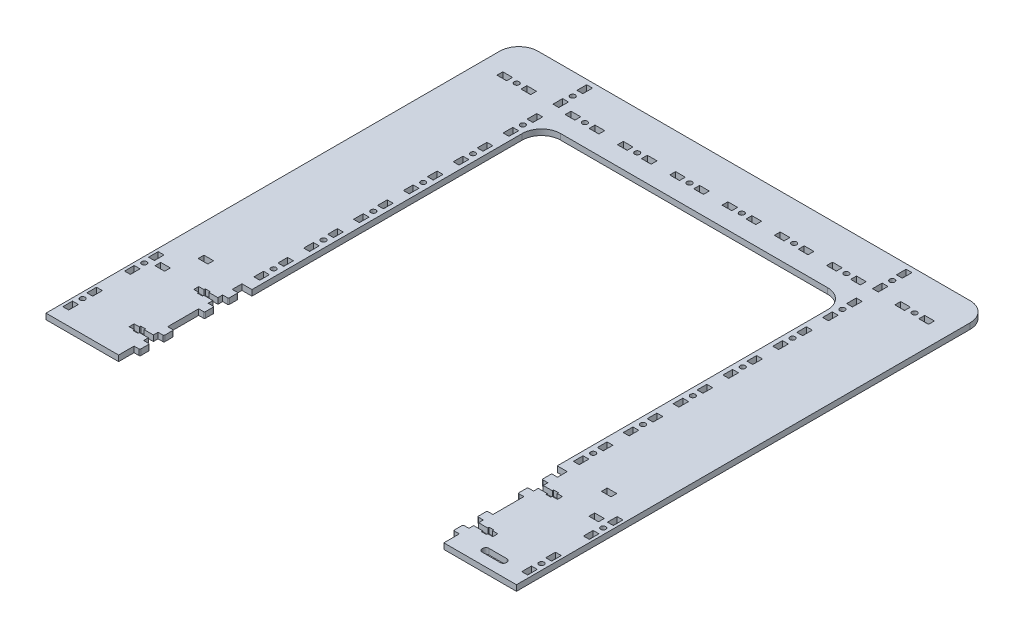
from build123d import *

# Parameters (mm, degrees)
SKETCH1_W                 = 490
SKETCH1_H                 = 492.5
BOSS_EXTRUDE1_DEPTH       = 6
SKETCH2_W                 = 338.8
SKETCH2_H                 = 128.5
CUT_EXTRUDE1_DEPTH        = 7
SKETCH3_W                 = 318
SKETCH3_H                 = 301.5
CUT_EXTRUDE2_DEPTH        = 7
M5_CLEARANCE_HOLE1_D      = 5.3
M5_CLEARANCE_HOLE2_D      = 5.3
SKETCH71_W                = 6.1
SKETCH71_H                = 10.1
CUT_EXTRUDE21_DEPTH       = 4
CUT_EXTRUDE21_DEPTH_BACK  = 4
SKETCH72_W                = 6.1
SKETCH72_H                = 10.1
CUT_EXTRUDE22_DEPTH       = 4
CUT_EXTRUDE22_DEPTH_BACK  = 4
SKETCH73_W                = 6.1
SKETCH73_H                = 10.1
CUT_EXTRUDE23_DEPTH       = 4
CUT_EXTRUDE23_DEPTH_BACK  = 4
SKETCH74_W                = 6.1
SKETCH74_H                = 10.1
CUT_EXTRUDE24_DEPTH       = 4
CUT_EXTRUDE24_DEPTH_BACK  = 4
CUT_EXTRUDE25_DEPTH       = 4
CUT_EXTRUDE25_DEPTH_BACK  = 4
SKETCH234_W               = 6.1
SKETCH234_H               = 10
BOSS_EXTRUDE2_DEPTH       = 3
BOSS_EXTRUDE2_DEPTH_BACK  = 3
FILLET1_R                 = 1
CUT_EXTRUDE26_DEPTH       = 4
CUT_EXTRUDE26_DEPTH_BACK  = 4
SKETCH2341_W              = 6.1
SKETCH2341_H              = 10
BOSS_EXTRUDE21_DEPTH      = 3
BOSS_EXTRUDE21_DEPTH_BACK = 3
FILLET11_R                = 1
CUT_EXTRUDE27_DEPTH       = 4
CUT_EXTRUDE27_DEPTH_BACK  = 4
SKETCH2342_W              = 6.1
SKETCH2342_H              = 10
BOSS_EXTRUDE22_DEPTH      = 3
BOSS_EXTRUDE22_DEPTH_BACK = 3
FILLET12_R                = 1
CUT_EXTRUDE28_DEPTH       = 4
CUT_EXTRUDE28_DEPTH_BACK  = 4
SKETCH2343_W              = 6.1
SKETCH2343_H              = 10
BOSS_EXTRUDE23_DEPTH      = 3
BOSS_EXTRUDE23_DEPTH_BACK = 3
FILLET13_R                = 1
SKETCH6_W                 = 10
SKETCH6_H                 = 6
CUT_EXTRUDE16_DEPTH       = 4
CUT_EXTRUDE16_DEPTH_BACK  = 4
SKETCH75_W                = 6.1
SKETCH75_H                = 10.1
CUT_EXTRUDE210_DEPTH      = 4
CUT_EXTRUDE210_DEPTH_BACK = 4
SKETCH76_W                = 6.1
SKETCH76_H                = 10.1
CUT_EXTRUDE211_DEPTH      = 4
CUT_EXTRUDE211_DEPTH_BACK = 4
SKETCH77_W                = 6.1
SKETCH77_H                = 10.1
CUT_EXTRUDE212_DEPTH      = 4
CUT_EXTRUDE212_DEPTH_BACK = 4
SKETCH78_W                = 6.1
SKETCH78_H                = 10.1
CUT_EXTRUDE213_DEPTH      = 4
CUT_EXTRUDE213_DEPTH_BACK = 4
SKETCH79_W                = 6.1
SKETCH79_H                = 10.1
CUT_EXTRUDE214_DEPTH      = 4
CUT_EXTRUDE214_DEPTH_BACK = 4
SKETCH710_W               = 6.1
SKETCH710_H               = 10.1
CUT_EXTRUDE215_DEPTH      = 4
CUT_EXTRUDE215_DEPTH_BACK = 4
SKETCH711_W               = 6.1
SKETCH711_H               = 10.1
CUT_EXTRUDE216_DEPTH      = 4
CUT_EXTRUDE216_DEPTH_BACK = 4
SKETCH712_W               = 6.1
SKETCH712_H               = 10.1
CUT_EXTRUDE217_DEPTH      = 4
CUT_EXTRUDE217_DEPTH_BACK = 4
SKETCH713_W               = 6.1
SKETCH713_H               = 10.1
CUT_EXTRUDE218_DEPTH      = 4
CUT_EXTRUDE218_DEPTH_BACK = 4
SKETCH714_W               = 6.1
SKETCH714_H               = 10.1
CUT_EXTRUDE219_DEPTH      = 4
CUT_EXTRUDE219_DEPTH_BACK = 4
SKETCH715_W               = 6.1
SKETCH715_H               = 10.1
CUT_EXTRUDE220_DEPTH      = 4
CUT_EXTRUDE220_DEPTH_BACK = 4
SKETCH716_W               = 6.1
SKETCH716_H               = 10.1
CUT_EXTRUDE221_DEPTH      = 4
CUT_EXTRUDE221_DEPTH_BACK = 4
SKETCH63_W                = 10
SKETCH63_H                = 6
CUT_EXTRUDE19_DEPTH       = 4
M5_CLEARANCE_HOLE3_D      = 5.3
SKETCH719_W               = 6.1
SKETCH719_H               = 10.1
CUT_EXTRUDE225_DEPTH      = 4
CUT_EXTRUDE225_DEPTH_BACK = 4
SKETCH720_W               = 6.1
SKETCH720_H               = 10.1
CUT_EXTRUDE226_DEPTH      = 4
CUT_EXTRUDE226_DEPTH_BACK = 4
SKETCH721_W               = 6.1
SKETCH721_H               = 10.1
CUT_EXTRUDE227_DEPTH      = 4
CUT_EXTRUDE227_DEPTH_BACK = 4
SKETCH722_W               = 6.1
SKETCH722_H               = 10.1
CUT_EXTRUDE228_DEPTH      = 4
CUT_EXTRUDE228_DEPTH_BACK = 4
SKETCH723_W               = 6.1
SKETCH723_H               = 10.1
CUT_EXTRUDE229_DEPTH      = 4
CUT_EXTRUDE229_DEPTH_BACK = 4
SKETCH724_W               = 6.1
SKETCH724_H               = 10.1
CUT_EXTRUDE230_DEPTH      = 4
CUT_EXTRUDE230_DEPTH_BACK = 4
SKETCH725_W               = 6.1
SKETCH725_H               = 10.1
CUT_EXTRUDE231_DEPTH      = 4
CUT_EXTRUDE231_DEPTH_BACK = 4
SKETCH718_W               = 6.1
SKETCH718_H               = 10.1
CUT_EXTRUDE224_DEPTH      = 4
CUT_EXTRUDE224_DEPTH_BACK = 4
SKETCH726_W               = 6.1
SKETCH726_H               = 10.1
CUT_EXTRUDE232_DEPTH      = 4
CUT_EXTRUDE232_DEPTH_BACK = 4
SKETCH727_W               = 6.1
SKETCH727_H               = 10.1
CUT_EXTRUDE233_DEPTH      = 4
CUT_EXTRUDE233_DEPTH_BACK = 4
FILLET14_R                = 20
SKETCH2351_W              = 25
SKETCH2351_H              = 7
CUT_EXTRUDE234_DEPTH      = 7
FILLET15_R                = 3
SKETCH65_W                = 10
SKETCH65_H                = 6
CUT_EXTRUDE111_DEPTH      = 4
CUT_EXTRUDE111_DEPTH_BACK = 4


with BuildPart() as part:
    # Sketch1 → Boss-Extrude1 (new body)
    with BuildSketch(Plane(origin=(0, 0, 0), x_dir=(1, 0, 0), z_dir=(0, 1, 0))):
        Rectangle(SKETCH1_W, SKETCH1_H)
    extrude(amount=BOSS_EXTRUDE1_DEPTH)

    # Sketch2 → Cut-Extrude1 (cut, through all)
    with BuildSketch(Plane(origin=(0, 6, 0), x_dir=(1, 0, 0), z_dir=(0, 1, 0))):
        with Locations((0, -182)):
            Rectangle(SKETCH2_W, SKETCH2_H)
    extrude(amount=-CUT_EXTRUDE1_DEPTH, mode=Mode.SUBTRACT)

    # Sketch3 → Cut-Extrude2 (cut, through all)
    with BuildSketch(Plane(origin=(0, 6, 0), x_dir=(1, 0, 0), z_dir=(0, 1, 0))):
        with Locations((0, 33)):
            Rectangle(SKETCH3_W, SKETCH3_H)
    extrude(amount=-CUT_EXTRUDE2_DEPTH, mode=Mode.SUBTRACT)

    # M5 Clearance Hole1 (through all)
    with Locations(Plane(origin=(0, 0, 0), x_dir=(-1, 0, 0), z_dir=(0, -1, 0))):
        with Locations((-239, -149.875), (-239, -214.125)):
            m5_clearance_hole1 = Hole(M5_CLEARANCE_HOLE1_D / 2)

    # M5 Clearance Hole2 (through all)
    with Locations(Plane(origin=(0, 6, 0), x_dir=(1, 0, 0), z_dir=(0, 1, 0))):
        with Locations((-166.4, -87.75), (-166.4, -35.833333333), (-166.4, 16.083333333), (-166.4, 68), (-166.4, 119.916666667), (-166.4, 171.833333333), (-166.4, 223.75)):
            m5_clearance_hole2 = Hole(M5_CLEARANCE_HOLE2_D / 2)

    # Mirror2: M5 Clearance Hole1, M5 Clearance Hole2 across plane
    add(m5_clearance_hole1.mirror(Plane(origin=(0, 0, 0), x_dir=(0, 0, 1), z_dir=(1, 0, 0))), mode=Mode.SUBTRACT)
    add(m5_clearance_hole2.mirror(Plane(origin=(0, 0, 0), x_dir=(0, 0, 1), z_dir=(1, 0, 0))), mode=Mode.SUBTRACT)

    # Sketch71 → Cut-Extrude21 (cut, two sides)
    with BuildSketch(Plane(origin=(283, 3, 169.875), x_dir=(-1, 0, 0), z_dir=(0, 1, 0))) as cut_extrude21_sk:
        with Locations((44, -32.5)):
            Rectangle(SKETCH71_W, SKETCH71_H)
        with Locations((44, -7.5)):
            Rectangle(SKETCH71_W, SKETCH71_H)
    extrude(amount=CUT_EXTRUDE21_DEPTH, mode=Mode.SUBTRACT)
    extrude(cut_extrude21_sk.sketch, amount=-CUT_EXTRUDE21_DEPTH_BACK, mode=Mode.SUBTRACT)

    # Sketch72 → Cut-Extrude22 (cut, two sides)
    with BuildSketch(Plane(origin=(283, 3, 234.125), x_dir=(-1, 0, 0), z_dir=(0, 1, 0))) as cut_extrude22_sk:
        with Locations((44, -32.5)):
            Rectangle(SKETCH72_W, SKETCH72_H)
        with Locations((44, -7.5)):
            Rectangle(SKETCH72_W, SKETCH72_H)
    extrude(amount=CUT_EXTRUDE22_DEPTH, mode=Mode.SUBTRACT)
    extrude(cut_extrude22_sk.sketch, amount=-CUT_EXTRUDE22_DEPTH_BACK, mode=Mode.SUBTRACT)

    # Sketch73 → Cut-Extrude23 (cut, two sides)
    with BuildSketch(Plane(origin=(-195, 3, 169.875), x_dir=(-1, 0, 0), z_dir=(0, 1, 0))) as cut_extrude23_sk:
        with Locations((44, -32.5)):
            Rectangle(SKETCH73_W, SKETCH73_H)
        with Locations((44, -7.5)):
            Rectangle(SKETCH73_W, SKETCH73_H)
    extrude(amount=CUT_EXTRUDE23_DEPTH, mode=Mode.SUBTRACT)
    extrude(cut_extrude23_sk.sketch, amount=-CUT_EXTRUDE23_DEPTH_BACK, mode=Mode.SUBTRACT)

    # Sketch74 → Cut-Extrude24 (cut, two sides)
    with BuildSketch(Plane(origin=(-195, 3, 234.125), x_dir=(-1, 0, 0), z_dir=(0, 1, 0))) as cut_extrude24_sk:
        with Locations((44, -32.5)):
            Rectangle(SKETCH74_W, SKETCH74_H)
        with Locations((44, -7.5)):
            Rectangle(SKETCH74_W, SKETCH74_H)
    extrude(amount=CUT_EXTRUDE24_DEPTH, mode=Mode.SUBTRACT)
    extrude(cut_extrude24_sk.sketch, amount=-CUT_EXTRUDE24_DEPTH_BACK, mode=Mode.SUBTRACT)

    # Sketch23 → Cut-Extrude25 (cut, two sides)
    with BuildSketch(Plane(origin=(219.4, 3, 165.375), x_dir=(-1, 0, 0), z_dir=(0, -1, 0))) as cut_extrude25_sk:
        Polygon((30, 17.4), (30, 22.6), (35.5, 22.6), (35.5, 24), (40.5, 24), (40.5, 22.6), (50, 22.6), (50, 17.4), (40.5, 17.4), (40.5, 16), (35.5, 16), (35.5, 17.4), align=None)
    extrude(amount=CUT_EXTRUDE25_DEPTH, mode=Mode.SUBTRACT)
    extrude(cut_extrude25_sk.sketch, amount=-CUT_EXTRUDE25_DEPTH_BACK, mode=Mode.SUBTRACT)

    # Sketch234 → Boss-Extrude2 (add, two sides)
    with BuildSketch(Plane(origin=(219.4, 3, 165.375), x_dir=(-1, 0, 0), z_dir=(0, -1, 0))) as boss_extrude2_sk:
        with Locations((53.05, 32.5)):
            Rectangle(SKETCH234_W, SKETCH234_H)
        with Locations((53.05, 7.5)):
            Rectangle(SKETCH234_W, SKETCH234_H)
    extrude(amount=BOSS_EXTRUDE2_DEPTH)
    extrude(boss_extrude2_sk.sketch, amount=-BOSS_EXTRUDE2_DEPTH_BACK)

    # Fillet1
    fillet1_edges = [part.edges().sort_by_distance(p)[0] for p in [
        (163.3, 3, 127.875),
        (163.3, 3, 137.875),
        (163.3, 3, 152.875),
        (163.3, 3, 162.875),
    ]]
    fillet(fillet1_edges, radius=FILLET1_R)

    # Sketch236 → Cut-Extrude26 (cut, two sides)
    with BuildSketch(Plane(origin=(219.4, 3, 232.625), x_dir=(-1, 0, 0), z_dir=(0, -1, 0))) as cut_extrude26_sk:
        Polygon((30, 17.4), (30, 22.6), (35.5, 22.6), (35.5, 24), (40.5, 24), (40.5, 22.6), (50, 22.6), (50, 17.4), (40.5, 17.4), (40.5, 16), (35.5, 16), (35.5, 17.4), align=None)
    extrude(amount=CUT_EXTRUDE26_DEPTH, mode=Mode.SUBTRACT)
    extrude(cut_extrude26_sk.sketch, amount=-CUT_EXTRUDE26_DEPTH_BACK, mode=Mode.SUBTRACT)

    # Sketch2341 → Boss-Extrude21 (add, two sides)
    with BuildSketch(Plane(origin=(219.4, 3, 232.625), x_dir=(-1, 0, 0), z_dir=(0, -1, 0))) as boss_extrude21_sk:
        with Locations((53.05, 32.5)):
            Rectangle(SKETCH2341_W, SKETCH2341_H)
        with Locations((53.05, 7.5)):
            Rectangle(SKETCH2341_W, SKETCH2341_H)
    extrude(amount=BOSS_EXTRUDE21_DEPTH)
    extrude(boss_extrude21_sk.sketch, amount=-BOSS_EXTRUDE21_DEPTH_BACK)

    # Fillet11
    fillet11_edges = [part.edges().sort_by_distance(p)[0] for p in [
        (163.3, 3, 195.125),
        (163.3, 3, 205.125),
        (163.3, 3, 220.125),
        (163.3, 3, 230.125),
    ]]
    fillet(fillet11_edges, radius=FILLET11_R)

    # Sketch237 → Cut-Extrude27 (cut, two sides)
    with BuildSketch(Plane(origin=(-219.4, 3, 125.375), x_dir=(1, 0, 0), z_dir=(0, -1, 0))) as cut_extrude27_sk:
        Polygon((30, 17.4), (30, 22.6), (35.5, 22.6), (35.5, 24), (40.5, 24), (40.5, 22.6), (50, 22.6), (50, 17.4), (40.5, 17.4), (40.5, 16), (35.5, 16), (35.5, 17.4), align=None)
    extrude(amount=CUT_EXTRUDE27_DEPTH, mode=Mode.SUBTRACT)
    extrude(cut_extrude27_sk.sketch, amount=-CUT_EXTRUDE27_DEPTH_BACK, mode=Mode.SUBTRACT)

    # Sketch2342 → Boss-Extrude22 (add, two sides)
    with BuildSketch(Plane(origin=(-219.4, 3, 125.375), x_dir=(1, 0, 0), z_dir=(0, -1, 0))) as boss_extrude22_sk:
        with Locations((53.05, 32.5)):
            Rectangle(SKETCH2342_W, SKETCH2342_H)
        with Locations((53.05, 7.5)):
            Rectangle(SKETCH2342_W, SKETCH2342_H)
    extrude(amount=BOSS_EXTRUDE22_DEPTH)
    extrude(boss_extrude22_sk.sketch, amount=-BOSS_EXTRUDE22_DEPTH_BACK)

    # Fillet12
    fillet12_edges = [part.edges().sort_by_distance(p)[0] for p in [
        (-163.3, 3, 162.875),
        (-163.3, 3, 152.875),
        (-163.3, 3, 137.875),
        (-163.3, 3, 127.875),
    ]]
    fillet(fillet12_edges, radius=FILLET12_R)

    # Sketch238 → Cut-Extrude28 (cut, two sides)
    with BuildSketch(Plane(origin=(-219.4, 3, 192.625), x_dir=(1, 0, 0), z_dir=(0, -1, 0))) as cut_extrude28_sk:
        Polygon((30, 17.4), (30, 22.6), (35.5, 22.6), (35.5, 24), (40.5, 24), (40.5, 22.6), (50, 22.6), (50, 17.4), (40.5, 17.4), (40.5, 16), (35.5, 16), (35.5, 17.4), align=None)
    extrude(amount=CUT_EXTRUDE28_DEPTH, mode=Mode.SUBTRACT)
    extrude(cut_extrude28_sk.sketch, amount=-CUT_EXTRUDE28_DEPTH_BACK, mode=Mode.SUBTRACT)

    # Sketch2343 → Boss-Extrude23 (add, two sides)
    with BuildSketch(Plane(origin=(-219.4, 3, 192.625), x_dir=(1, 0, 0), z_dir=(0, -1, 0))) as boss_extrude23_sk:
        with Locations((53.05, 32.5)):
            Rectangle(SKETCH2343_W, SKETCH2343_H)
        with Locations((53.05, 7.5)):
            Rectangle(SKETCH2343_W, SKETCH2343_H)
    extrude(amount=BOSS_EXTRUDE23_DEPTH)
    extrude(boss_extrude23_sk.sketch, amount=-BOSS_EXTRUDE23_DEPTH_BACK)

    # Fillet13
    fillet13_edges = [part.edges().sort_by_distance(p)[0] for p in [
        (-163.3, 3, 230.125),
        (-163.3, 3, 220.125),
        (-163.3, 3, 205.125),
        (-163.3, 3, 195.125),
    ]]
    fillet(fillet13_edges, radius=FILLET13_R)

    # Sketch6 → Cut-Extrude16 (cut, two sides)
    with BuildSketch(Plane(origin=(209.232221392, 3, 70.75), x_dir=(1, 0, 0), z_dir=(0, 1, 0))) as cut_extrude16_sk:
        with Locations((0.767778608, -44)):
            Rectangle(SKETCH6_W, SKETCH6_H)
    extrude(amount=CUT_EXTRUDE16_DEPTH, mode=Mode.SUBTRACT)
    extrude(cut_extrude16_sk.sketch, amount=-CUT_EXTRUDE16_DEPTH_BACK, mode=Mode.SUBTRACT)

    # Sketch75 → Cut-Extrude210 (cut, two sides)
    with BuildSketch(Plane(origin=(122.4, 3, 107.75), x_dir=(1, 0, 0), z_dir=(0, -1, 0))) as cut_extrude210_sk:
        with Locations((44, -32.5)):
            Rectangle(SKETCH75_W, SKETCH75_H)
        with Locations((44, -7.5)):
            Rectangle(SKETCH75_W, SKETCH75_H)
    extrude(amount=CUT_EXTRUDE210_DEPTH, mode=Mode.SUBTRACT)
    extrude(cut_extrude210_sk.sketch, amount=-CUT_EXTRUDE210_DEPTH_BACK, mode=Mode.SUBTRACT)

    # Sketch76 → Cut-Extrude211 (cut, two sides)
    with BuildSketch(Plane(origin=(122.4, 3, 55.833333333), x_dir=(1, 0, 0), z_dir=(0, -1, 0))) as cut_extrude211_sk:
        with Locations((44, -32.5)):
            Rectangle(SKETCH76_W, SKETCH76_H)
        with Locations((44, -7.5)):
            Rectangle(SKETCH76_W, SKETCH76_H)
    extrude(amount=CUT_EXTRUDE211_DEPTH, mode=Mode.SUBTRACT)
    extrude(cut_extrude211_sk.sketch, amount=-CUT_EXTRUDE211_DEPTH_BACK, mode=Mode.SUBTRACT)

    # Sketch77 → Cut-Extrude212 (cut, two sides)
    with BuildSketch(Plane(origin=(122.4, 3, 3.916666667), x_dir=(1, 0, 0), z_dir=(0, -1, 0))) as cut_extrude212_sk:
        with Locations((44, -32.5)):
            Rectangle(SKETCH77_W, SKETCH77_H)
        with Locations((44, -7.5)):
            Rectangle(SKETCH77_W, SKETCH77_H)
    extrude(amount=CUT_EXTRUDE212_DEPTH, mode=Mode.SUBTRACT)
    extrude(cut_extrude212_sk.sketch, amount=-CUT_EXTRUDE212_DEPTH_BACK, mode=Mode.SUBTRACT)

    # Sketch78 → Cut-Extrude213 (cut, two sides)
    with BuildSketch(Plane(origin=(122.4, 3, -48), x_dir=(1, 0, 0), z_dir=(0, -1, 0))) as cut_extrude213_sk:
        with Locations((44, -32.5)):
            Rectangle(SKETCH78_W, SKETCH78_H)
        with Locations((44, -7.5)):
            Rectangle(SKETCH78_W, SKETCH78_H)
    extrude(amount=CUT_EXTRUDE213_DEPTH, mode=Mode.SUBTRACT)
    extrude(cut_extrude213_sk.sketch, amount=-CUT_EXTRUDE213_DEPTH_BACK, mode=Mode.SUBTRACT)

    # Sketch79 → Cut-Extrude214 (cut, two sides)
    with BuildSketch(Plane(origin=(122.4, 3, -99.916666667), x_dir=(1, 0, 0), z_dir=(0, -1, 0))) as cut_extrude214_sk:
        with Locations((44, -32.5)):
            Rectangle(SKETCH79_W, SKETCH79_H)
        with Locations((44, -7.5)):
            Rectangle(SKETCH79_W, SKETCH79_H)
    extrude(amount=CUT_EXTRUDE214_DEPTH, mode=Mode.SUBTRACT)
    extrude(cut_extrude214_sk.sketch, amount=-CUT_EXTRUDE214_DEPTH_BACK, mode=Mode.SUBTRACT)

    # Sketch710 → Cut-Extrude215 (cut, two sides)
    with BuildSketch(Plane(origin=(122.4, 3, -151.833333333), x_dir=(1, 0, 0), z_dir=(0, -1, 0))) as cut_extrude215_sk:
        with Locations((44, -32.5)):
            Rectangle(SKETCH710_W, SKETCH710_H)
        with Locations((44, -7.5)):
            Rectangle(SKETCH710_W, SKETCH710_H)
    extrude(amount=CUT_EXTRUDE215_DEPTH, mode=Mode.SUBTRACT)
    extrude(cut_extrude215_sk.sketch, amount=-CUT_EXTRUDE215_DEPTH_BACK, mode=Mode.SUBTRACT)

    # Sketch711 → Cut-Extrude216 (cut, two sides)
    with BuildSketch(Plane(origin=(-210.4, 3, 107.75), x_dir=(1, 0, 0), z_dir=(0, -1, 0))) as cut_extrude216_sk:
        with Locations((44, -32.5)):
            Rectangle(SKETCH711_W, SKETCH711_H)
        with Locations((44, -7.5)):
            Rectangle(SKETCH711_W, SKETCH711_H)
    extrude(amount=CUT_EXTRUDE216_DEPTH, mode=Mode.SUBTRACT)
    extrude(cut_extrude216_sk.sketch, amount=-CUT_EXTRUDE216_DEPTH_BACK, mode=Mode.SUBTRACT)

    # Sketch712 → Cut-Extrude217 (cut, two sides)
    with BuildSketch(Plane(origin=(-210.4, 3, 55.833333333), x_dir=(1, 0, 0), z_dir=(0, -1, 0))) as cut_extrude217_sk:
        with Locations((44, -32.5)):
            Rectangle(SKETCH712_W, SKETCH712_H)
        with Locations((44, -7.5)):
            Rectangle(SKETCH712_W, SKETCH712_H)
    extrude(amount=CUT_EXTRUDE217_DEPTH, mode=Mode.SUBTRACT)
    extrude(cut_extrude217_sk.sketch, amount=-CUT_EXTRUDE217_DEPTH_BACK, mode=Mode.SUBTRACT)

    # Sketch713 → Cut-Extrude218 (cut, two sides)
    with BuildSketch(Plane(origin=(-210.4, 3, 3.916666667), x_dir=(1, 0, 0), z_dir=(0, -1, 0))) as cut_extrude218_sk:
        with Locations((44, -32.5)):
            Rectangle(SKETCH713_W, SKETCH713_H)
        with Locations((44, -7.5)):
            Rectangle(SKETCH713_W, SKETCH713_H)
    extrude(amount=CUT_EXTRUDE218_DEPTH, mode=Mode.SUBTRACT)
    extrude(cut_extrude218_sk.sketch, amount=-CUT_EXTRUDE218_DEPTH_BACK, mode=Mode.SUBTRACT)

    # Sketch714 → Cut-Extrude219 (cut, two sides)
    with BuildSketch(Plane(origin=(-210.4, 3, -48), x_dir=(1, 0, 0), z_dir=(0, -1, 0))) as cut_extrude219_sk:
        with Locations((44, -32.5)):
            Rectangle(SKETCH714_W, SKETCH714_H)
        with Locations((44, -7.5)):
            Rectangle(SKETCH714_W, SKETCH714_H)
    extrude(amount=CUT_EXTRUDE219_DEPTH, mode=Mode.SUBTRACT)
    extrude(cut_extrude219_sk.sketch, amount=-CUT_EXTRUDE219_DEPTH_BACK, mode=Mode.SUBTRACT)

    # Sketch715 → Cut-Extrude220 (cut, two sides)
    with BuildSketch(Plane(origin=(-210.4, 3, -99.916666667), x_dir=(1, 0, 0), z_dir=(0, -1, 0))) as cut_extrude220_sk:
        with Locations((44, -32.5)):
            Rectangle(SKETCH715_W, SKETCH715_H)
        with Locations((44, -7.5)):
            Rectangle(SKETCH715_W, SKETCH715_H)
    extrude(amount=CUT_EXTRUDE220_DEPTH, mode=Mode.SUBTRACT)
    extrude(cut_extrude220_sk.sketch, amount=-CUT_EXTRUDE220_DEPTH_BACK, mode=Mode.SUBTRACT)

    # Sketch716 → Cut-Extrude221 (cut, two sides)
    with BuildSketch(Plane(origin=(-210.4, 3, -151.833333333), x_dir=(1, 0, 0), z_dir=(0, -1, 0))) as cut_extrude221_sk:
        with Locations((44, -32.5)):
            Rectangle(SKETCH716_W, SKETCH716_H)
        with Locations((44, -7.5)):
            Rectangle(SKETCH716_W, SKETCH716_H)
    extrude(amount=CUT_EXTRUDE221_DEPTH, mode=Mode.SUBTRACT)
    extrude(cut_extrude221_sk.sketch, amount=-CUT_EXTRUDE221_DEPTH_BACK, mode=Mode.SUBTRACT)

    # Sketch63 → Cut-Extrude19 (cut, symmetric)
    with BuildSketch(Plane(origin=(225.232221392, 3, 99.75), x_dir=(1, 0, 0), z_dir=(0, 1, 0))):
        with Locations((0.767778608, -44)):
            Rectangle(SKETCH63_W, SKETCH63_H)
    cut_extrude19 = extrude(amount=CUT_EXTRUDE19_DEPTH, both=True, mode=Mode.SUBTRACT)

    # Mirror3: Cut-Extrude19 across plane
    add(cut_extrude19.mirror(Plane(origin=(0, 0, 0), x_dir=(0, 0, 1), z_dir=(1, 0, 0))), mode=Mode.SUBTRACT)

    # M5 Clearance Hole3 (through all)
    with Locations(Plane(origin=(0, 6, 0), x_dir=(1, 0, 0), z_dir=(0, 1, 0))):
        with Locations((207.2, 206.25), (136.166666667, 206.25), (81.7, 206.25), (27.233333333, 206.25)):
            m5_clearance_hole3 = Hole(M5_CLEARANCE_HOLE3_D / 2)

    # Mirror4: M5 Clearance Hole3 across plane
    add(m5_clearance_hole3.mirror(Plane(origin=(0, 0, 0), x_dir=(0, 0, 1), z_dir=(1, 0, 0))), mode=Mode.SUBTRACT)

    # Sketch719 → Cut-Extrude225 (cut, two sides)
    with BuildSketch(Plane(origin=(116.166666667, 3, -162.25), x_dir=(0, 0, -1), z_dir=(0, 1, 0))) as cut_extrude225_sk:
        with Locations((44, -32.5)):
            Rectangle(SKETCH719_W, SKETCH719_H)
        with Locations((44, -7.5)):
            Rectangle(SKETCH719_W, SKETCH719_H)
    extrude(amount=CUT_EXTRUDE225_DEPTH, mode=Mode.SUBTRACT)
    extrude(cut_extrude225_sk.sketch, amount=-CUT_EXTRUDE225_DEPTH_BACK, mode=Mode.SUBTRACT)

    # Sketch720 → Cut-Extrude226 (cut, two sides)
    with BuildSketch(Plane(origin=(61.7, 3, -162.25), x_dir=(0, 0, -1), z_dir=(0, 1, 0))) as cut_extrude226_sk:
        with Locations((44, -32.5)):
            Rectangle(SKETCH720_W, SKETCH720_H)
        with Locations((44, -7.5)):
            Rectangle(SKETCH720_W, SKETCH720_H)
    extrude(amount=CUT_EXTRUDE226_DEPTH, mode=Mode.SUBTRACT)
    extrude(cut_extrude226_sk.sketch, amount=-CUT_EXTRUDE226_DEPTH_BACK, mode=Mode.SUBTRACT)

    # Sketch721 → Cut-Extrude227 (cut, two sides)
    with BuildSketch(Plane(origin=(7.233333333, 3, -162.25), x_dir=(0, 0, -1), z_dir=(0, 1, 0))) as cut_extrude227_sk:
        with Locations((44, -32.5)):
            Rectangle(SKETCH721_W, SKETCH721_H)
        with Locations((44, -7.5)):
            Rectangle(SKETCH721_W, SKETCH721_H)
    extrude(amount=CUT_EXTRUDE227_DEPTH, mode=Mode.SUBTRACT)
    extrude(cut_extrude227_sk.sketch, amount=-CUT_EXTRUDE227_DEPTH_BACK, mode=Mode.SUBTRACT)

    # Sketch722 → Cut-Extrude228 (cut, two sides)
    with BuildSketch(Plane(origin=(-47.233333333, 3, -162.25), x_dir=(0, 0, -1), z_dir=(0, 1, 0))) as cut_extrude228_sk:
        with Locations((44, -32.5)):
            Rectangle(SKETCH722_W, SKETCH722_H)
        with Locations((44, -7.5)):
            Rectangle(SKETCH722_W, SKETCH722_H)
    extrude(amount=CUT_EXTRUDE228_DEPTH, mode=Mode.SUBTRACT)
    extrude(cut_extrude228_sk.sketch, amount=-CUT_EXTRUDE228_DEPTH_BACK, mode=Mode.SUBTRACT)

    # Sketch723 → Cut-Extrude229 (cut, two sides)
    with BuildSketch(Plane(origin=(-101.7, 3, -162.25), x_dir=(0, 0, -1), z_dir=(0, 1, 0))) as cut_extrude229_sk:
        with Locations((44, -32.5)):
            Rectangle(SKETCH723_W, SKETCH723_H)
        with Locations((44, -7.5)):
            Rectangle(SKETCH723_W, SKETCH723_H)
    extrude(amount=CUT_EXTRUDE229_DEPTH, mode=Mode.SUBTRACT)
    extrude(cut_extrude229_sk.sketch, amount=-CUT_EXTRUDE229_DEPTH_BACK, mode=Mode.SUBTRACT)

    # Sketch724 → Cut-Extrude230 (cut, two sides)
    with BuildSketch(Plane(origin=(-156.166666667, 3, -162.25), x_dir=(0, 0, -1), z_dir=(0, 1, 0))) as cut_extrude230_sk:
        with Locations((44, -32.5)):
            Rectangle(SKETCH724_W, SKETCH724_H)
        with Locations((44, -7.5)):
            Rectangle(SKETCH724_W, SKETCH724_H)
    extrude(amount=CUT_EXTRUDE230_DEPTH, mode=Mode.SUBTRACT)
    extrude(cut_extrude230_sk.sketch, amount=-CUT_EXTRUDE230_DEPTH_BACK, mode=Mode.SUBTRACT)

    # Sketch725 → Cut-Extrude231 (cut, two sides)
    with BuildSketch(Plane(origin=(-227.2, 3, -162.25), x_dir=(0, 0, -1), z_dir=(0, 1, 0))) as cut_extrude231_sk:
        with Locations((44, -32.5)):
            Rectangle(SKETCH725_W, SKETCH725_H)
        with Locations((44, -7.5)):
            Rectangle(SKETCH725_W, SKETCH725_H)
    extrude(amount=CUT_EXTRUDE231_DEPTH, mode=Mode.SUBTRACT)
    extrude(cut_extrude231_sk.sketch, amount=-CUT_EXTRUDE231_DEPTH_BACK, mode=Mode.SUBTRACT)

    # Sketch718 → Cut-Extrude224 (cut, two sides)
    with BuildSketch(Plane(origin=(187.2, 3, -162.25), x_dir=(0, 0, -1), z_dir=(0, 1, 0))) as cut_extrude224_sk:
        with Locations((44, -32.5)):
            Rectangle(SKETCH718_W, SKETCH718_H)
        with Locations((44, -7.5)):
            Rectangle(SKETCH718_W, SKETCH718_H)
    extrude(amount=CUT_EXTRUDE224_DEPTH, mode=Mode.SUBTRACT)
    extrude(cut_extrude224_sk.sketch, amount=-CUT_EXTRUDE224_DEPTH_BACK, mode=Mode.SUBTRACT)

    # Sketch726 → Cut-Extrude232 (cut, two sides)
    with BuildSketch(Plane(origin=(122.4, 3, -203.75), x_dir=(1, 0, 0), z_dir=(0, -1, 0))) as cut_extrude232_sk:
        with Locations((44, -32.5)):
            Rectangle(SKETCH726_W, SKETCH726_H)
        with Locations((44, -7.5)):
            Rectangle(SKETCH726_W, SKETCH726_H)
    extrude(amount=CUT_EXTRUDE232_DEPTH, mode=Mode.SUBTRACT)
    extrude(cut_extrude232_sk.sketch, amount=-CUT_EXTRUDE232_DEPTH_BACK, mode=Mode.SUBTRACT)

    # Sketch727 → Cut-Extrude233 (cut, two sides)
    with BuildSketch(Plane(origin=(-210.4, 3, -203.75), x_dir=(1, 0, 0), z_dir=(0, -1, 0))) as cut_extrude233_sk:
        with Locations((44, -32.5)):
            Rectangle(SKETCH727_W, SKETCH727_H)
        with Locations((44, -7.5)):
            Rectangle(SKETCH727_W, SKETCH727_H)
    extrude(amount=CUT_EXTRUDE233_DEPTH, mode=Mode.SUBTRACT)
    extrude(cut_extrude233_sk.sketch, amount=-CUT_EXTRUDE233_DEPTH_BACK, mode=Mode.SUBTRACT)

    # Fillet14
    fillet14_edges = [part.edges().sort_by_distance(p)[0] for p in [
        (-159, 3, -183.75),
        (159, 3, -183.75),
        (-245, 3, -246.25),
        (245, 3, -246.25),
    ]]
    fillet(fillet14_edges, radius=FILLET14_R)

    # Sketch2351 → Cut-Extrude234 (cut, through all)
    with BuildSketch(Plane(origin=(0, 6, 0), x_dir=(1, 0, 0), z_dir=(0, 1, 0))):
        with Locations((207.2, -231.25)):
            Rectangle(SKETCH2351_W, SKETCH2351_H)
    extrude(amount=-CUT_EXTRUDE234_DEPTH, mode=Mode.SUBTRACT)

    # Fillet15
    fillet15_edges = [part.edges().sort_by_distance(p)[0] for p in [
        (219.7, 3, 227.75),
        (219.7, 3, 234.75),
        (194.7, 3, 234.75),
        (194.7, 3, 227.75),
    ]]
    fillet(fillet15_edges, radius=FILLET15_R)

    # Sketch65 → Cut-Extrude111 (cut, two sides)
    with BuildSketch(Plane(origin=(-210.767778608, 3, 70.75), x_dir=(1, 0, 0), z_dir=(0, 1, 0))) as cut_extrude111_sk:
        with Locations((0.767778608, -44)):
            Rectangle(SKETCH65_W, SKETCH65_H)
    extrude(amount=CUT_EXTRUDE111_DEPTH, mode=Mode.SUBTRACT)
    extrude(cut_extrude111_sk.sketch, amount=-CUT_EXTRUDE111_DEPTH_BACK, mode=Mode.SUBTRACT)


solid = part.part
